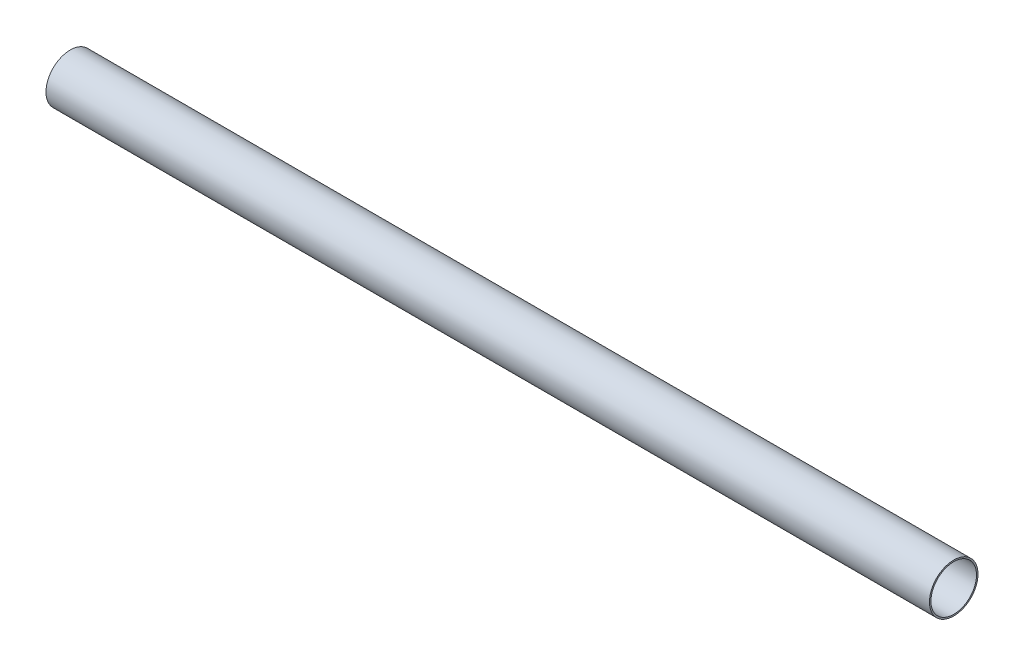
from build123d import *

# Parameters (mm, degrees)
SKETCH1_W = 564
SKETCH1_H = 0.95


with BuildPart() as part:
    # Sketch1 → Revolve1 (revolve)
    with BuildSketch(Plane.XY):
        with Locations((-134.224299065, 15.025)):
            Rectangle(SKETCH1_W, SKETCH1_H)
    revolve(axis=Axis((147.775700935, 0, 0), (-1, 0, 0)))


solid = part.part
